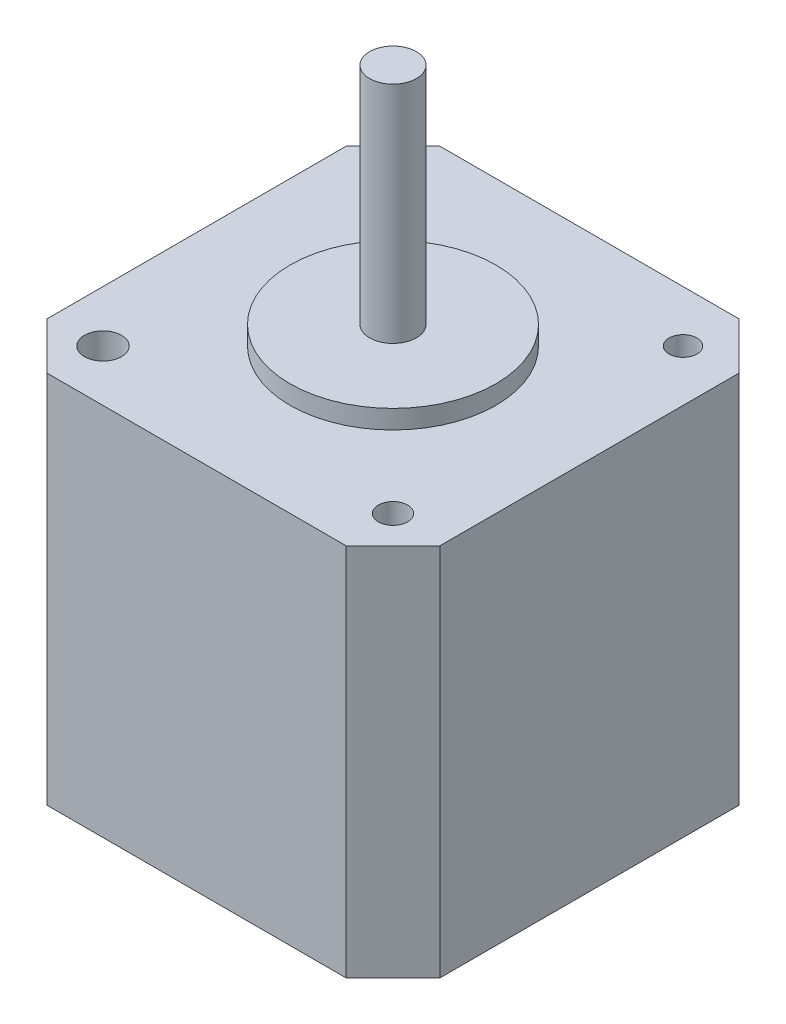
from build123d import *

# Parameters (mm, degrees)
SKETCH1_W           = 42
SKETCH1_H           = 42
BOSS_EXTRUDE1_DEPTH = 40
CHAMFER1_SIZE       = 5
SKETCH2_R           = 11
BOSS_EXTRUDE2_DEPTH = 2
SKETCH3_R           = 1.490042647
SKETCH3_R_2         = 1.56185503
SKETCH3_R_3         = 1.981129843
SKETCH3_R_4         = 1.582833873
CUT_EXTRUDE1_DEPTH  = 8
SKETCH4_R           = 2.5
BOSS_EXTRUDE3_DEPTH = 24


with BuildPart() as part:
    # Sketch1 → Boss-Extrude1 (new body)
    with BuildSketch(Plane(origin=(0, 0, 0), x_dir=(1, 0, 0), z_dir=(0, 1, 0))):
        Rectangle(SKETCH1_W, SKETCH1_H)
    extrude(amount=BOSS_EXTRUDE1_DEPTH)

    # Chamfer1
    chamfer1_edges = [part.edges().sort_by_distance(p)[0] for p in [
        (-21, 20, -21),
        (21, 20, -21),
        (21, 20, 21),
        (-21, 20, 21),
    ]]
    chamfer(chamfer1_edges, length=CHAMFER1_SIZE)

    # Sketch2 → Boss-Extrude2 (add)
    with BuildSketch(Plane(origin=(0, 40, 0), x_dir=(1, 0, 0), z_dir=(0, 1, 0))):
        Circle(SKETCH2_R)
    extrude(amount=BOSS_EXTRUDE2_DEPTH)

    # Sketch3 → Cut-Extrude1 (cut)
    with BuildSketch(Plane(origin=(0, 40, 0), x_dir=(1, 0, 0), z_dir=(0, 1, 0))):
        with Locations((15.5, 15.5)):
            Circle(SKETCH3_R)
        with Locations((15.5, -15.5)):
            Circle(SKETCH3_R_2)
        with Locations((-15.5, -15.5)):
            Circle(SKETCH3_R_3)
        with Locations((-15.5, 15.5)):
            Circle(SKETCH3_R_4)
    extrude(amount=-CUT_EXTRUDE1_DEPTH, mode=Mode.SUBTRACT)

    # Sketch4 → Boss-Extrude3 (add)
    with BuildSketch(Plane(origin=(0, 42, 0), x_dir=(1, 0, 0), z_dir=(0, 1, 0))):
        Circle(SKETCH4_R)
    extrude(amount=BOSS_EXTRUDE3_DEPTH)


solid = part.part
